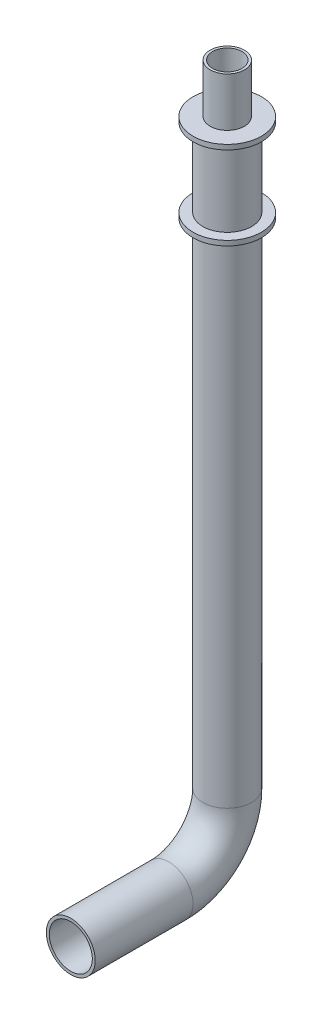
from build123d import *

# Parameters (mm, degrees)
SKETCH9_R           = 25
SKETCH9_R_2         = 22
SKETCH10_R          = 35
BOSS_EXTRUDE1_DEPTH = 5
SKETCH11_R          = 17.5
SKETCH11_R_2        = 15
EXTRUDE_THIN1_DEPTH = 50


with BuildPart() as part:
    # Sweep-Thin1: sweep along a path in Sketch2
    with BuildLine(Plane(origin=(0, 0, 0), x_dir=(0, 0, -1), z_dir=(1, 0, 0))) as sweep_thin1_path:
        Line((-160, 0), (-60, 0))
        ThreePointArc((-60, 0), (-17.573593129, 17.573593129), (0, 60))
        Line((0, 60), (0, 650))
    # Sketch9 → Sweep-Thin1 (sweep)
    with BuildSketch(Plane(origin=(0, 650, 0), x_dir=(1, 0, 0), z_dir=(0, 1, 0))):
        Circle(SKETCH9_R)
        Circle(SKETCH9_R_2, mode=Mode.SUBTRACT)
    sweep(path=sweep_thin1_path.line)

    # Sketch10 → Boss-Extrude1 (add)
    with BuildSketch(Plane(origin=(0, 650, 0), x_dir=(1, 0, 0), z_dir=(0, 1, 0))):
        Circle(SKETCH10_R)
    boss_extrude1 = extrude(amount=BOSS_EXTRUDE1_DEPTH)

    # Sketch11 → Extrude-Thin1 (add)
    with BuildSketch(Plane(origin=(0, 655, 0), x_dir=(1, 0, 0), z_dir=(0, 1, 0))):
        Circle(SKETCH11_R)
        Circle(SKETCH11_R_2, mode=Mode.SUBTRACT)
    extrude(amount=EXTRUDE_THIN1_DEPTH)

    # Mirror1: Boss-Extrude1 across plane
    add(boss_extrude1.mirror(Plane.ZX.offset(610)))


solid = part.part
